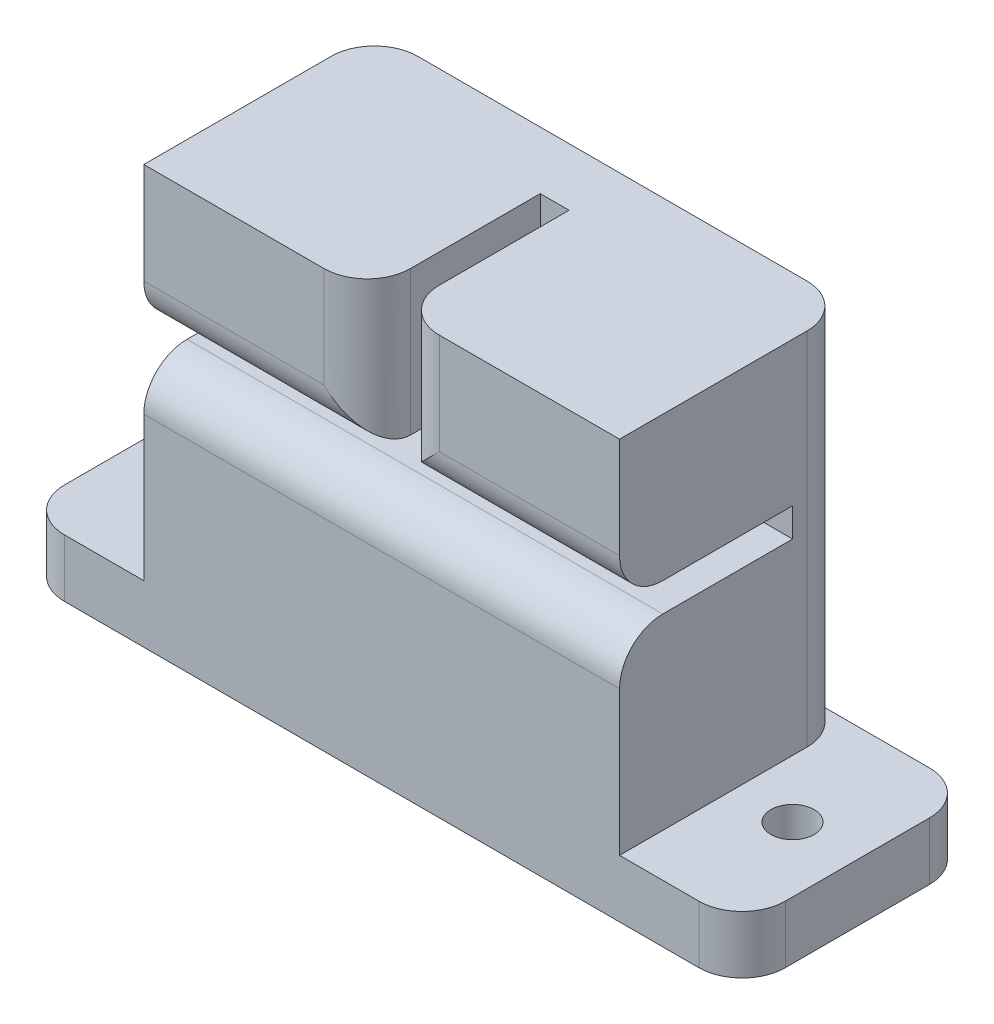
from build123d import *

# Parameters (mm, degrees)
EXTRUDE1_DEPTH = 16
EXTRUDE6_DEPTH = 12
SKETCH3_R      = 1.5
EXTRUDE7_DEPTH = 4
FILLET1_R      = 3
FILLET2_R      = 3


with BuildPart() as part:
    # Sketch1 → Extrude1 (new body)
    with BuildSketch(Plane.XY):
        Polygon((16.5, -10.5), (25, -10.5), (25, -14.5), (-25, -14.5), (-25, -10.5), (-16.5, -10.5), (-16.5, 14.5), (16.5, 14.5), align=None)
    extrude(amount=-EXTRUDE1_DEPTH)

    # Sketch2 → Extrude6 (cut)
    with BuildSketch(Plane.XY):
        Polygon((1, 14.5), (-1, 14.5), (-1, 4.5), (-16.5, 4.5), (-16.5, 2.5), (16.5, 2.5), (16.5, 4.5), (1, 4.5), align=None)
    extrude(amount=-EXTRUDE6_DEPTH, mode=Mode.SUBTRACT)

    # Sketch3 → Extrude7 (cut)
    with BuildSketch(Plane.XZ.offset(14.5)):
        with Locations((-20.5, -8)):
            Circle(SKETCH3_R)
        with Locations((20.5, -8)):
            Circle(SKETCH3_R)
    extrude(amount=-EXTRUDE7_DEPTH, mode=Mode.SUBTRACT)

    # Fillet1
    fillet1_edges = [part.edges().sort_by_distance(p)[0] for p in [
        (-1, 9.5, 0),
        (8.75, 4.5, 0),
        (-8.75, 4.5, 0),
        (0, 2.5, 0),
        (1, 9.5, 0),
    ]]
    fillet(fillet1_edges, radius=FILLET1_R)

    # Fillet2
    fillet2_edges = [part.edges().sort_by_distance(p)[0] for p in [
        (-25, -12.5, 0),
        (-16.5, 2, -16),
        (-25, -12.5, -16),
        (25, -12.5, -16),
        (16.5, 2, -16),
        (25, -12.5, 0),
    ]]
    fillet(fillet2_edges, radius=FILLET2_R)


solid = part.part
